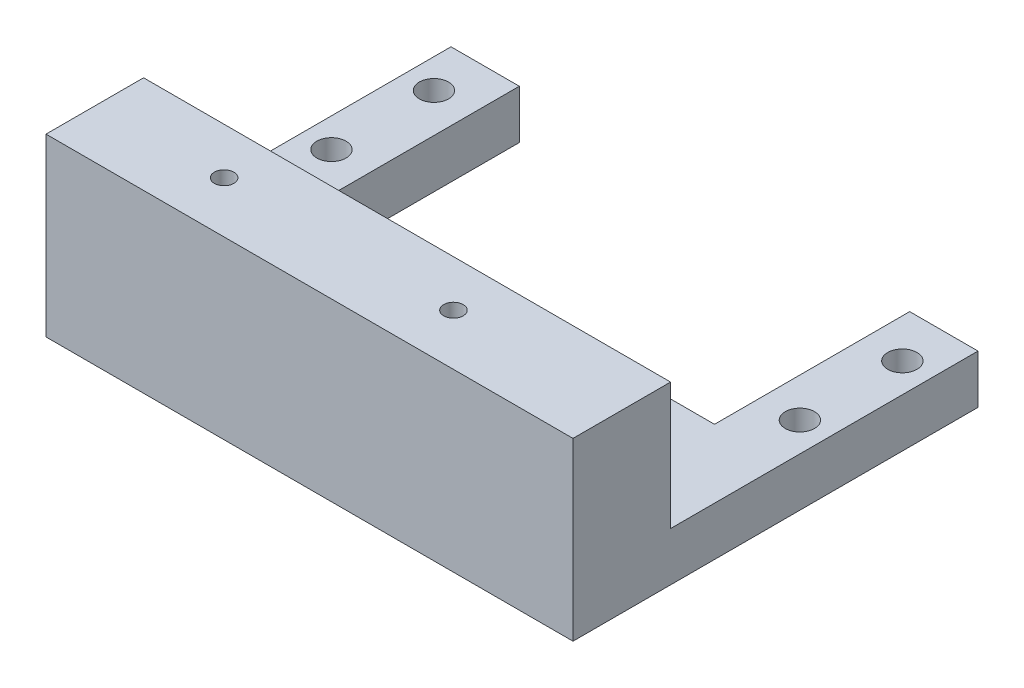
from build123d import *

# Parameters (mm, degrees)
BOSS_EXTRUDE1_DEPTH = 5
SKETCH2_R           = 1.5
CUT_EXTRUDE1_DEPTH  = 6
SKETCH3_W           = 54
SKETCH3_H           = 10
BOSS_EXTRUDE2_DEPTH = 13
SKETCH4_R           = 1
CUT_EXTRUDE2_DEPTH  = 6


with BuildPart() as part:
    # Sketch1 → Boss-Extrude1 (new body)
    with BuildSketch(Plane(origin=(0, 0, 0), x_dir=(1, 0, 0), z_dir=(0, 1, 0))):
        Polygon((-20, 20.75), (-20, 0.75), (20, 0.75), (20, 20.75), (27, 20.75), (27, -20.75), (-27, -20.75), (-27, 20.75), align=None)
    extrude(amount=BOSS_EXTRUDE1_DEPTH)

    # Sketch2 → Cut-Extrude1 (cut, through all)
    with BuildSketch(Plane(origin=(0, 5, 0), x_dir=(1, 0, 0), z_dir=(0, 1, 0))):
        with Locations((-24, 16)):
            Circle(SKETCH2_R)
        with Locations((-24, 5.5)):
            Circle(SKETCH2_R)
        with Locations((24, 16)):
            Circle(SKETCH2_R)
        with Locations((24, 5.5)):
            Circle(SKETCH2_R)
    extrude(amount=-CUT_EXTRUDE1_DEPTH, mode=Mode.SUBTRACT)

    # Sketch3 → Boss-Extrude2 (add)
    with BuildSketch(Plane(origin=(0, 5, 0), x_dir=(1, 0, 0), z_dir=(0, 1, 0))):
        with Locations((0, -15.75)):
            Rectangle(SKETCH3_W, SKETCH3_H)
    extrude(amount=BOSS_EXTRUDE2_DEPTH)

    # Sketch4 → Cut-Extrude2 (cut)
    with BuildSketch(Plane(origin=(0, 18, 0), x_dir=(1, 0, 0), z_dir=(0, 1, 0))):
        with Locations((-14, -15.5)):
            Circle(SKETCH4_R)
        with Locations((9.5, -15.5)):
            Circle(SKETCH4_R)
    extrude(amount=-CUT_EXTRUDE2_DEPTH, mode=Mode.SUBTRACT)


solid = part.part
